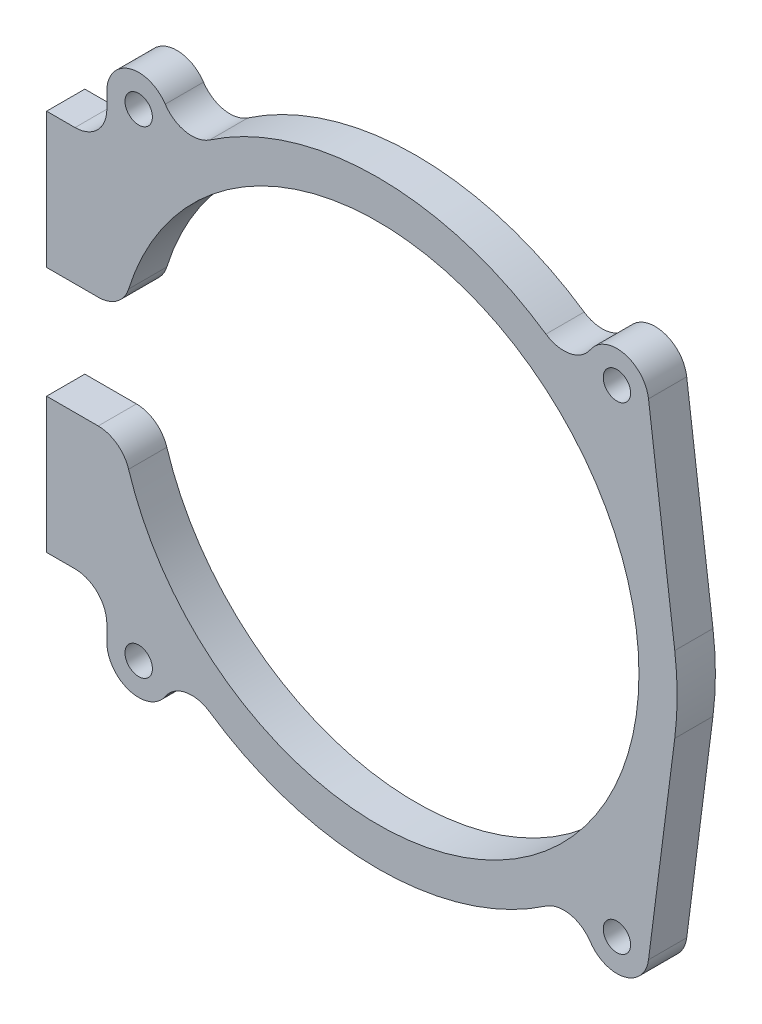
from build123d import *

# Parameters (mm, degrees)
SKETCH_1_R      = 2.15
EXTRUDE_1_DEPTH = 6


with BuildPart() as part:
    # 草图1 → 凸台-拉伸1 (new body)
    with BuildSketch(Plane.XY):
        with BuildLine():
            ThreePointArc((-43.896896246, -8.75), (-40.93656063, -9.720556733), (-39.12549448, -12.255434783))
            ThreePointArc((-39.12549448, -12.255434783), (41, 0), (-39.12549448, 12.255434783))
            ThreePointArc((-39.12549448, 12.255434783), (-40.93656063, 9.720556733), (-43.896896246, 8.75))
            Line((-43.896896246, 8.75), (-52, 8.75))
            Line((-52, 8.75), (-52, 30))
            Line((-52, 30), (-47.54, 30))
            ThreePointArc((-47.54, 30), (-44.004466094, 31.464466094), (-42.54, 35))
            Line((-42.54, 35), (-42.54, 37.5))
            ThreePointArc((-42.54, 37.5), (-38.982425028, 42.287422066), (-33.372235985, 40.262198963))
            ThreePointArc((-33.372235985, 40.262198963), (-30.171244586, 38.118753147), (-26.396349665, 38.887436588))
            ThreePointArc((-26.396349665, 38.887436588), (0, 47), (26.396349665, 38.887436588))
            ThreePointArc((26.396349665, 38.887436588), (30.171244586, 38.118753147), (33.372235985, 40.262198963))
            ThreePointArc((33.372235985, 40.262198963), (38.674773042, 42.369526686), (42.499484755, 38.135225128))
            Line((42.499484755, 38.135225128), (46.619156699, 5.971116201))
            ThreePointArc((46.619156699, 5.971116201), (47, 0), (46.619156699, -5.971116201))
            Line((46.619156699, -5.971116201), (42.499484755, -38.135225128))
            ThreePointArc((42.499484755, -38.135225128), (38.674773042, -42.369526686), (33.372235985, -40.262198963))
            ThreePointArc((33.372235985, -40.262198963), (30.171244586, -38.118753147), (26.396349665, -38.887436588))
            ThreePointArc((26.396349665, -38.887436588), (0, -47), (-26.396349665, -38.887436588))
            ThreePointArc((-26.396349665, -38.887436588), (-30.171244586, -38.118753147), (-33.372235985, -40.262198963))
            ThreePointArc((-33.372235985, -40.262198963), (-38.982425028, -42.287422066), (-42.54, -37.5))
            Line((-42.54, -37.5), (-42.54, -35))
            ThreePointArc((-42.54, -35), (-44.004466094, -31.464466094), (-47.54, -30))
            Line((-47.54, -30), (-52, -30))
            Line((-52, -30), (-52, -8.75))
            Line((-52, -8.75), (-43.896896246, -8.75))
        make_face()
        with Locations((37.54, -37.5)):
            Circle(SKETCH_1_R, mode=Mode.SUBTRACT)
        with Locations((-37.54, -37.5)):
            Circle(SKETCH_1_R, mode=Mode.SUBTRACT)
        with Locations((-37.54, 37.5)):
            Circle(SKETCH_1_R, mode=Mode.SUBTRACT)
        with Locations((37.54, 37.5)):
            Circle(SKETCH_1_R, mode=Mode.SUBTRACT)
    extrude(amount=EXTRUDE_1_DEPTH)


solid = part.part
